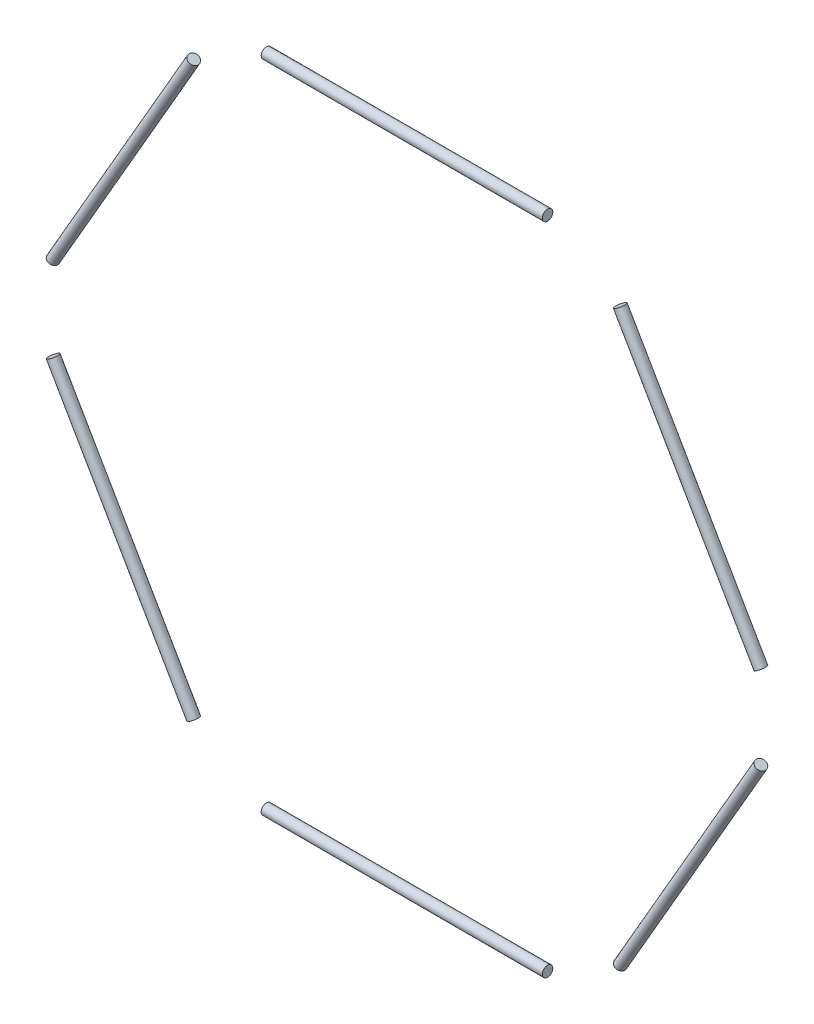
from build123d import *

# Parameters (mm, degrees)
MASTER_SKETCH_W   = 48.347295252
MASTER_SKETCH_H   = 0.9
CIRPATTERN1_COUNT = 6


with BuildPart() as part:
    # Master Sketch → Revolve1 (revolve)
    with BuildSketch(Plane.XY):
        with Locations((0, 56.75)):
            Rectangle(MASTER_SKETCH_W, MASTER_SKETCH_H)
    revolve(axis=Axis((-24.173647626, 56.3, 0), (1, 0, 0)))


with BuildPart() as cirpattern1_1:
    # CirPattern1: pattern copy
    add(part.part.rotate(Axis((0, 0, 0), (0, 0, 1)), 1 * 360 / CIRPATTERN1_COUNT))


with BuildPart() as cirpattern1_2:
    # CirPattern1: pattern copy
    add(part.part.rotate(Axis((0, 0, 0), (0, 0, 1)), 2 * 360 / CIRPATTERN1_COUNT))


with BuildPart() as cirpattern1_3:
    # CirPattern1: pattern copy
    add(part.part.rotate(Axis((0, 0, 0), (0, 0, 1)), 3 * 360 / CIRPATTERN1_COUNT))


with BuildPart() as cirpattern1_4:
    # CirPattern1: pattern copy
    add(part.part.rotate(Axis((0, 0, 0), (0, 0, 1)), 4 * 360 / CIRPATTERN1_COUNT))


with BuildPart() as cirpattern1_5:
    # CirPattern1: pattern copy
    add(part.part.rotate(Axis((0, 0, 0), (0, 0, 1)), 5 * 360 / CIRPATTERN1_COUNT))


solid = Compound([part.part, cirpattern1_1.part, cirpattern1_2.part, cirpattern1_3.part, cirpattern1_4.part, cirpattern1_5.part])
